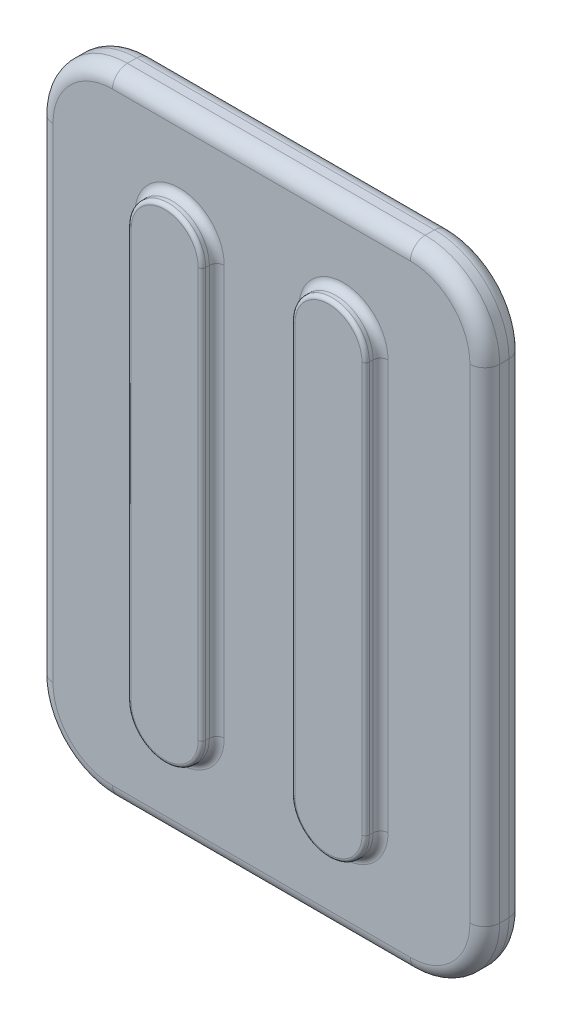
from build123d import *

# Parameters (mm, degrees)
SKETCH_1_W      = 600
SKETCH_1_H      = 850
EXTRUDE_1_DEPTH = 52.484908593
EXTRUDE_2_DEPTH = 20
FILLET_1_R      = 100
FILLET_2_R      = 10
FILLET_3_R      = 5
FILLET_4_R      = 20
EXTRUDE_START   = -100
EXTRUDE_3_DEPTH = 670
SCALE_1_SCALE   = 0.111111111


with BuildPart() as part:
    # 草图1 → 凸台-拉伸1 (new body)
    with BuildSketch(Plane.XY):
        Rectangle(SKETCH_1_W, SKETCH_1_H)
    extrude(amount=EXTRUDE_1_DEPTH)

    # 草图2 → 凸台-拉伸2 (add)
    with BuildSketch(Plane.XY.offset(52.484908593)):
        with BuildLine():
            Line((-60, 275), (-60, -275))
            ThreePointArc((-60, -275), (-110, -325), (-160, -275))
            Line((-160, -275), (-160, 275))
            ThreePointArc((-160, 275), (-110, 325), (-60, 275))
        make_face()
        with BuildLine():
            Line((60, 275), (60, -275))
            ThreePointArc((60, -275), (110, -325), (160, -275))
            Line((160, -275), (160, 275))
            ThreePointArc((160, 275), (110, 325), (60, 275))
        make_face()
    extrude(amount=EXTRUDE_2_DEPTH)

    # 圆角1
    fillet_1_edges = [part.edges().sort_by_distance(p)[0] for p in [
        (300, -425, 26.242454296),
        (-300, -425, 26.242454296),
        (-300, 425, 26.242454296),
        (300, 425, 26.242454296),
    ]]
    fillet(fillet_1_edges, radius=FILLET_1_R)

    # 圆角2
    fillet_2_edges = [part.edges().sort_by_distance(p)[0] for p in [
        (-110, 325, 52.484908593),
        (-160, 0, 52.484908593),
        (-110, -325, 52.484908593),
        (-60, 0, 52.484908593),
        (110, 325, 52.484908593),
        (60, 0, 52.484908593),
        (110, -325, 52.484908593),
        (160, 0, 52.484908593),
    ]]
    fillet(fillet_2_edges, radius=FILLET_2_R)

    # 圆角3
    fillet_3_edges = [part.edges().sort_by_distance(p)[0] for p in [
        (-110, 325, 72.484908593),
        (-160, 0, 72.484908593),
        (-110, -325, 72.484908593),
        (-60, 0, 72.484908593),
        (110, 325, 72.484908593),
        (60, 0, 72.484908593),
        (110, -325, 72.484908593),
        (160, 0, 72.484908593),
    ]]
    fillet(fillet_3_edges, radius=FILLET_3_R)

    # 圆角4
    fillet_4_edges = [part.edges().sort_by_distance(p)[0] for p in [
        (0, 425, 0),
        (0, 425, 52.484908593),
        (300, 0, 0),
        (0, -425, 0),
        (-300, 0, 0),
        (-270.710678119, -395.710678119, 0),
        (270.710678119, -395.710678119, 0),
        (-270.710678119, 395.710678119, 0),
        (270.710678119, 395.710678119, 0),
        (300, 0, 52.484908593),
        (-300, 0, 52.484908593),
        (0, -425, 52.484908593),
        (-270.710678119, -395.710678119, 52.484908593),
        (270.710678119, -395.710678119, 52.484908593),
        (-270.710678119, 395.710678119, 52.484908593),
        (270.710678119, 395.710678119, 52.484908593),
    ]]
    fillet(fillet_4_edges, radius=FILLET_4_R)

    # 草图3 → 凸台-拉伸3 (add)
    with BuildSketch(Plane(origin=(0, 425, 0), x_dir=(1, 0, 0), z_dir=(0, 1, 0)).offset(EXTRUDE_START)):
        Polygon((-159.75, 0), (-110.25, 0), (-110.25, 7.38), (-122.225, 19.39), (-147.775, 19.39), (-159.75, 7.38), align=None)
        Polygon((159.75, 0), (159.75, 7.38), (147.775, 19.39), (122.225, 19.39), (110.25, 7.38), (110.25, 0), align=None)
    extrude(amount=-EXTRUDE_3_DEPTH)


with BuildPart() as part_1:
    # 缩放比例1: scaled about (0, -0.370563428, 28.072026876)
    add(part.part.scale(SCALE_1_SCALE).moved(Location((0, -0.329389714, 24.952912779))))


solid = part_1.part
